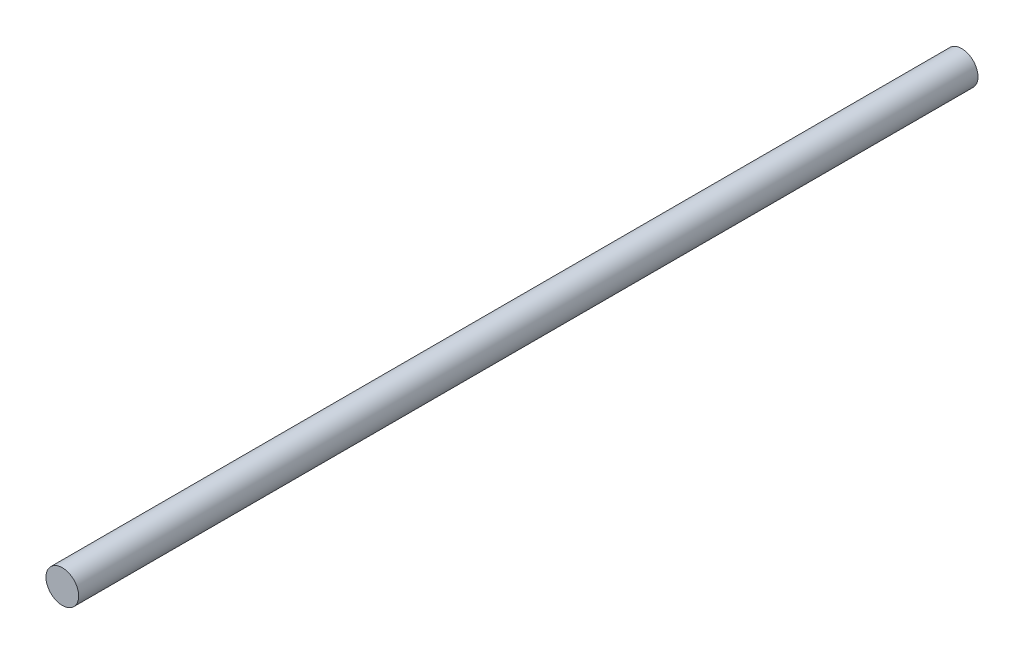
from build123d import *

# Parameters (mm, degrees)
ESBO_O1_R                = 4
RESSALTO_EXTRUS_O1_DEPTH = 220


with BuildPart() as part:
    # Esboço1 → Ressalto-extrusão1 (new body)
    with BuildSketch(Plane.XY):
        Circle(ESBO_O1_R)
    extrude(amount=RESSALTO_EXTRUS_O1_DEPTH)


solid = part.part
